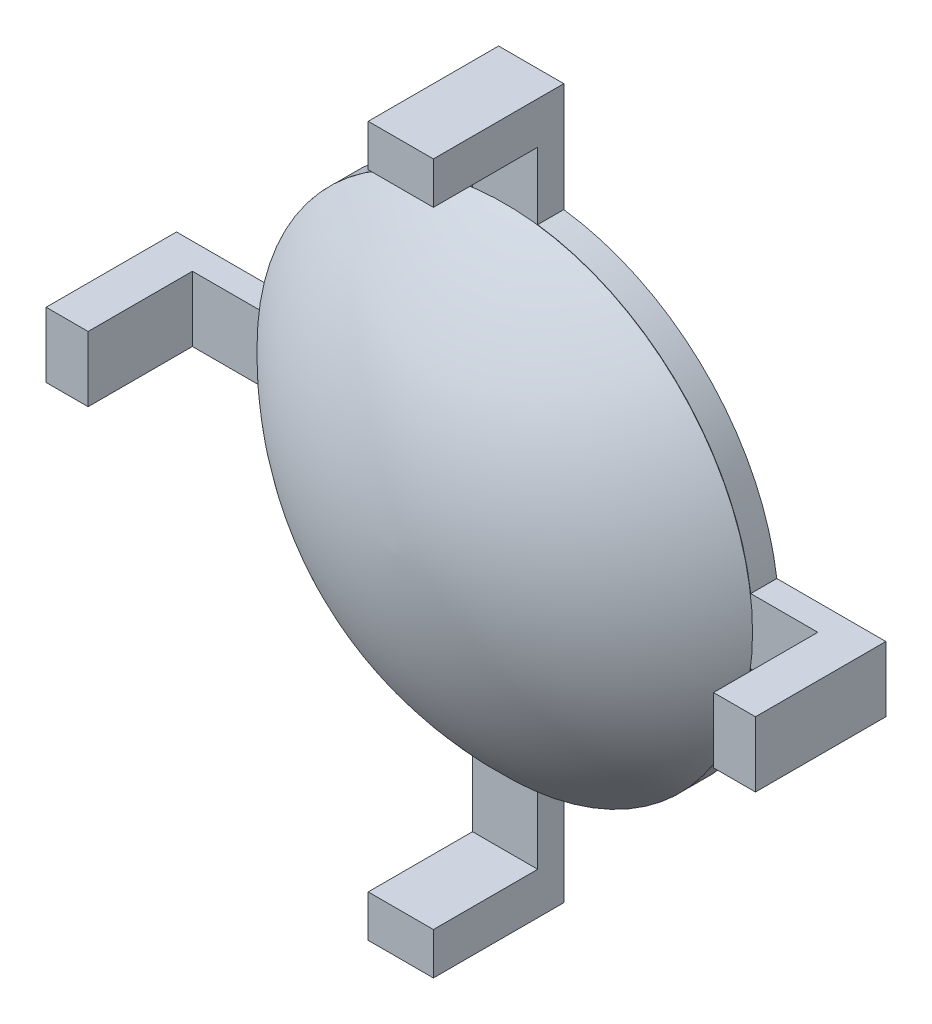
from build123d import *

# Parameters (mm, degrees)
SKETCH1_R           = 9.5
SKETCH1_W           = 27.2
SKETCH1_H           = 2.5
SKETCH1_W_2         = 2.5
SKETCH1_H_2         = 27.2
BOSS_EXTRUDE1_DEPTH = 1
SKETCH2_W           = 1.609397648
SKETCH2_H           = 2.5
SKETCH2_W_2         = 2.5
SKETCH2_H_2         = 1.609397648
BOSS_EXTRUDE2_DEPTH = 4


with BuildPart() as part:
    # Sketch1 → Boss-Extrude1 (new body)
    with BuildSketch(Plane.XY):
        Circle(SKETCH1_R)
        Rectangle(SKETCH1_W, SKETCH1_H)
        Rectangle(SKETCH1_W_2, SKETCH1_H_2)
    extrude(amount=BOSS_EXTRUDE1_DEPTH)

    # Sketch2 → Boss-Extrude2 (add)
    with BuildSketch(Plane.XY.offset(1)):
        with Locations((-12.795301176, 0)):
            Rectangle(SKETCH2_W, SKETCH2_H)
        with Locations((0, 12.795301176)):
            Rectangle(SKETCH2_W_2, SKETCH2_H_2)
        with Locations((12.795301176, 0)):
            Rectangle(SKETCH2_W, SKETCH2_H)
        with Locations((0, -12.795301176)):
            Rectangle(SKETCH2_W_2, SKETCH2_H_2)
    extrude(amount=BOSS_EXTRUDE2_DEPTH)


with BuildPart() as body_2:
    # Sketch7 → Revolve4 (revolve)
    with BuildSketch(Plane(origin=(0, 0, 0), x_dir=(1, 0, 0), z_dir=(0, 1, 0))):
        with BuildLine():
            Line((-0.000156816, -1.011901345), (-9.500156816, -1.011901345))
            ThreePointArc((-9.500156816, -1.011901345), (-5.167752239, -4.056462422), (-0.000156816, -5.211901345))
            Line((-0.000156816, -5.211901345), (-0.000156816, -1.011901345))
        make_face()
    revolve(axis=Axis((-0.000156816, 0, 5.211901345), (0, 0, 1)))


solid = Compound([part.part, body_2.part])
